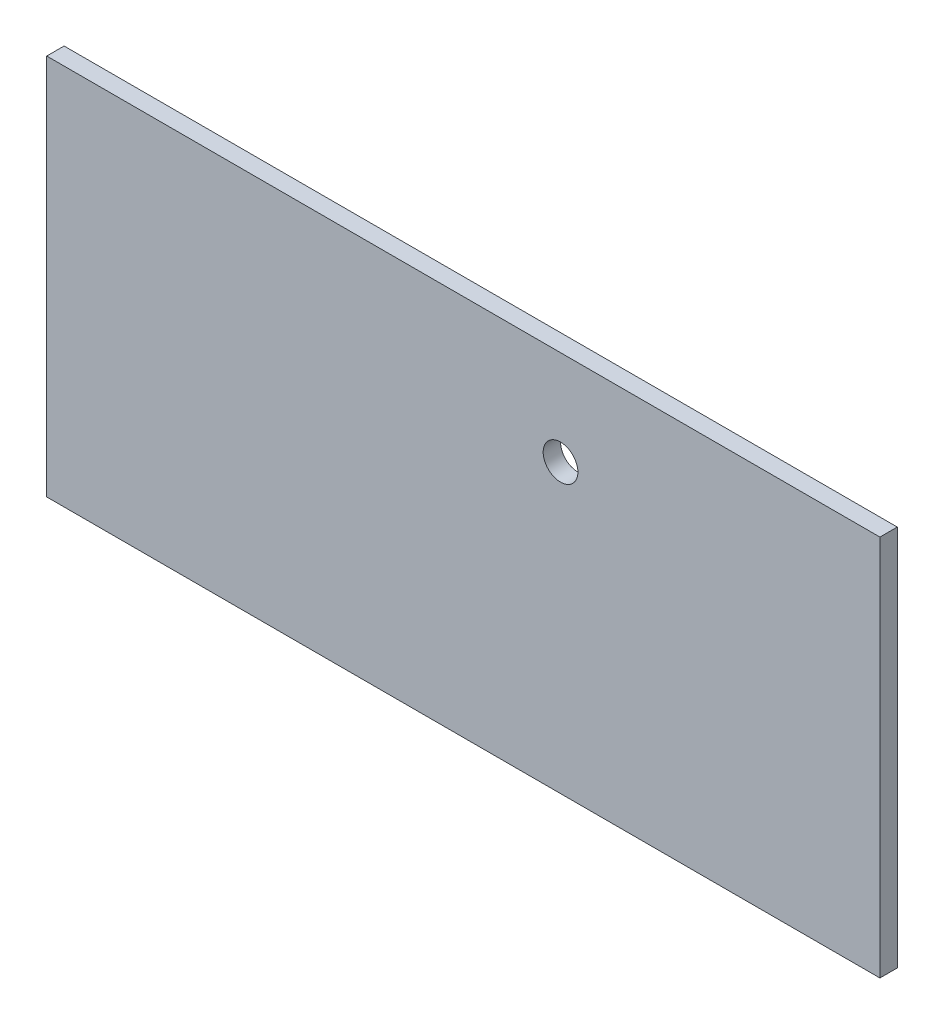
from build123d import *

# Parameters (mm, degrees)
ESQUISSE1_W             = 240
ESQUISSE1_H             = 50
BOSS_EXTRU_1_DEPTH      = 5
ESQUISSE2_W             = 240
ESQUISSE2_H             = 5
BOSS_EXTRU_2_DEPTH      = 50
ESQUISSE4_R             = 5
ENL_V_MAT_EXTRU_1_DEPTH = 5
ESQUISSE5_W             = 240
ESQUISSE5_H             = 5
BOSS_EXTRU_3_DEPTH      = 10


with BuildPart() as part:
    # Esquisse1 → Boss.-Extru.1 (new body)
    with BuildSketch(Plane.XY):
        with Locations((-120, 25)):
            Rectangle(ESQUISSE1_W, ESQUISSE1_H)
    extrude(amount=BOSS_EXTRU_1_DEPTH)

    # Esquisse2 → Boss.-Extru.2 (add)
    with BuildSketch(Plane(origin=(0, 50, 0), x_dir=(1, 0, 0), z_dir=(0, 1, 0))):
        with Locations((-120, -2.5)):
            Rectangle(ESQUISSE2_W, ESQUISSE2_H)
    extrude(amount=BOSS_EXTRU_2_DEPTH)

    # Esquisse4 → Enlèv. mat.-Extru.1 (cut)
    with BuildSketch(Plane.XY.offset(5)):
        with Locations((-92, 82.7)):
            Circle(ESQUISSE4_R)
    extrude(amount=-ENL_V_MAT_EXTRU_1_DEPTH, mode=Mode.SUBTRACT)

    # Esquisse5 → Boss.-Extru.3 (add)
    with BuildSketch(Plane(origin=(0, 100, 0), x_dir=(1, 0, 0), z_dir=(0, 1, 0))):
        with Locations((-120, -2.5)):
            Rectangle(ESQUISSE5_W, ESQUISSE5_H)
    extrude(amount=BOSS_EXTRU_3_DEPTH)


solid = part.part
